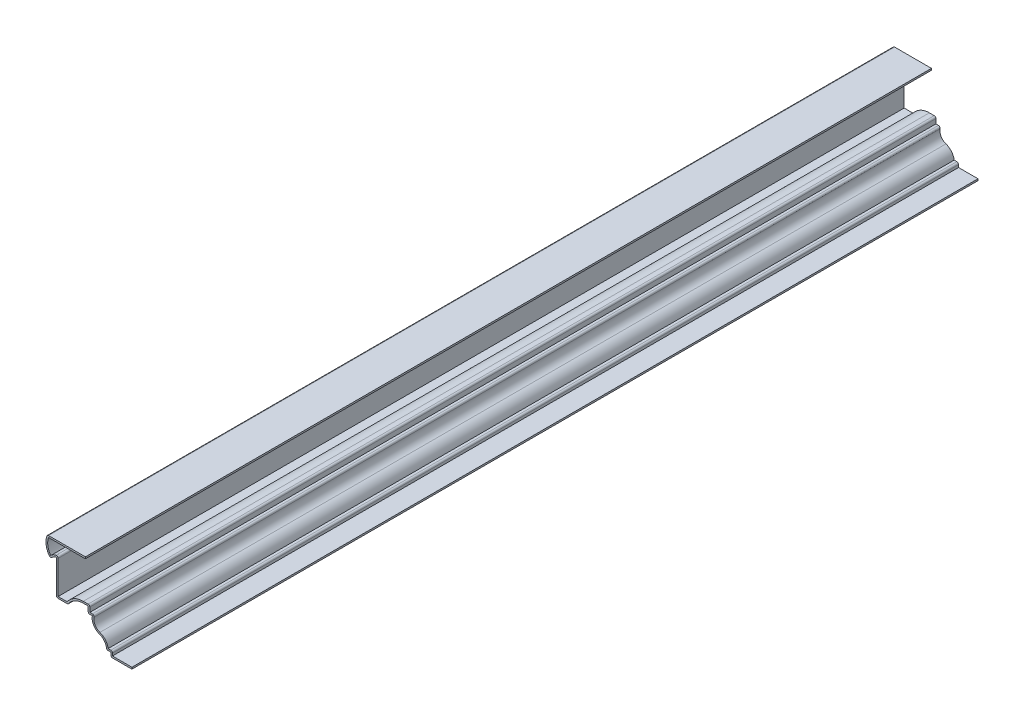
from build123d import *

# Parameters (mm, degrees)
EXTRUDE_THIN1_DEPTH = 635
FILLET1_R           = 1.27


with BuildPart() as part:
    # Sketch1 → Extrude-Thin1 (new body)
    with BuildSketch(Plane.XY):
        with BuildLine():
            Line((0, 0), (-15.875, 0))
            Line((-15.875, 0), (-15.875, 3.175))
            Line((-15.875, 3.175), (-19.05, 3.175))
            ThreePointArc((-19.05, 3.175), (-20.540376263, 7.805172974), (-24.451827217, 10.69658692))
            ThreePointArc((-24.451827217, 10.69658692), (-28.805679852, 14.276302994), (-29.685414913, 19.84375))
            Line((-29.685414913, 19.84375), (-32.860414913, 19.84375))
            Line((-32.860414913, 19.84375), (-32.860414913, 24.60625))
            Line((-32.860414913, 24.60625), (-36.494039614, 24.60625))
            ThreePointArc((-36.494039614, 24.60625), (-43.039469794, 22.912442068), (-47.941664913, 18.25625))
            Line((-47.941664913, 18.25625), (-56.672914913, 18.25625))
            Line((-56.672914913, 18.25625), (-56.672914913, 44.351036989))
            ThreePointArc((-56.672914913, 44.351036989), (-59.143520033, 43.316980719), (-60.876574207, 41.275))
            ThreePointArc((-60.876574207, 41.275), (-64.274926573, 48.035607826), (-63.5, 55.5625))
            Line((-63.5, 55.5625), (-34.925, 55.5625))
            Line((-34.925, 55.5625), (-34.925, 54.2925))
            Line((-34.925, 54.2925), (-62.614600616, 54.2925))
            ThreePointArc((-62.614600616, 54.2925), (-63.088488589, 48.638883567), (-60.958941974, 43.380273504))
            ThreePointArc((-60.958941974, 43.380273504), (-58.440775835, 45.159436942), (-55.402914913, 45.686679074))
            Line((-55.402914913, 45.686679074), (-55.402914913, 19.52625))
            Line((-55.402914913, 19.52625), (-48.62569758, 19.52625))
            ThreePointArc((-48.62569758, 19.52625), (-43.340564736, 24.19276788), (-36.494039614, 25.87625))
            Line((-36.494039614, 25.87625), (-31.590414913, 25.87625))
            Line((-31.590414913, 25.87625), (-31.590414913, 21.11375))
            Line((-31.590414913, 21.11375), (-27.922084416, 21.11375))
            ThreePointArc((-27.922084416, 21.11375), (-28.061990954, 15.63278224), (-24.046119572, 11.900040827))
            ThreePointArc((-24.046119572, 11.900040827), (-19.898030583, 9.05015784), (-17.868006799, 4.445))
            Line((-17.868006799, 4.445), (-14.605, 4.445))
            Line((-14.605, 4.445), (-14.605, 1.27))
            Line((-14.605, 1.27), (0, 1.27))
            Line((0, 1.27), (0, 0))
        make_face()
    extrude(amount=-EXTRUDE_THIN1_DEPTH)

    # Fillet1
    fillet1_edges = [part.edges().sort_by_distance(p)[0] for p in [
        (-55.402914913, 45.686679074, -317.5),
        (-31.590414913, 25.87625, -317.5),
        (-27.922084416, 21.11375, -317.5),
        (-14.605, 4.445, -317.5),
        (-15.875, 0, -317.5),
        (-19.05, 3.175, -317.5),
        (-32.860414913, 19.84375, -317.5),
        (-47.941664913, 18.25625, -317.5),
        (-56.672914913, 18.25625, -317.5),
        (-60.876574207, 41.275, -317.5),
        (-63.5, 55.5625, -317.5),
    ]]
    fillet(fillet1_edges, radius=FILLET1_R)


solid = part.part
